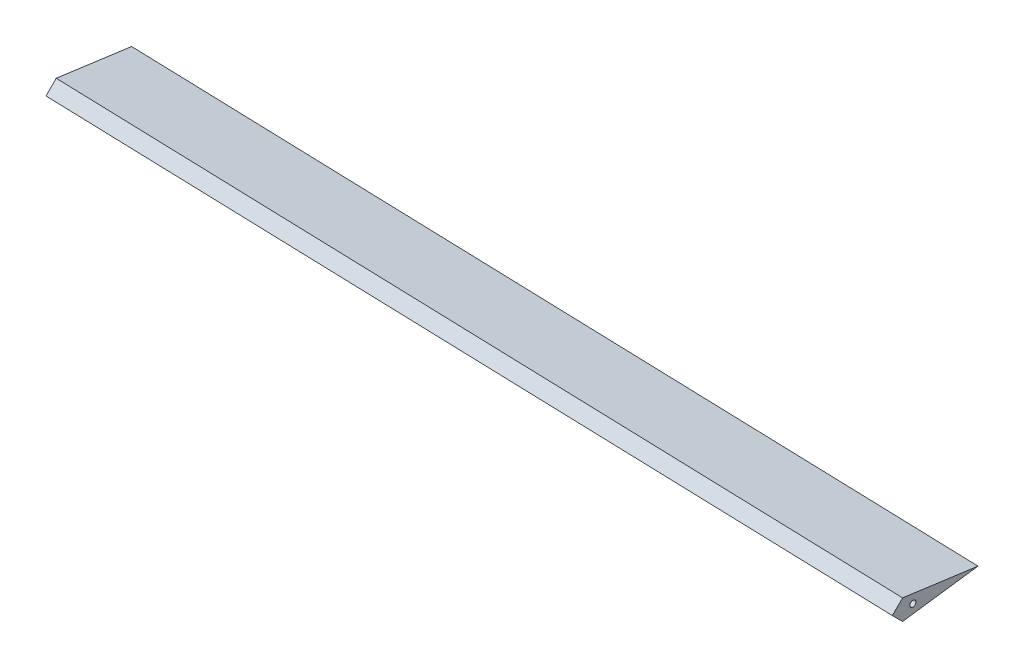
from build123d import *

# Parameters (mm, degrees)
AILERON_DEPTH           = 402.822020631
SKETCH2_R               = 2.75
CUT_EXTRUDE2_DEPTH      = 403.822020631
CUT_EXTRUDE2_DEPTH_BACK = 406.280098


with BuildPart() as part:
    # aileron_root → aileron (new body, symmetric, along a direction that is not the sketch's normal)
    with BuildSketch(Plane(origin=(0, 0, 0), x_dir=(0, 0, -1), z_dir=(1, 0, 0))):
        Polygon((-80, -10.846932253), (-80, 10.846932253), (0, 0), align=None)
    extrude(amount=AILERON_DEPTH, dir=(0.999527846, 0, 0.030725967), both=True)

    # Sketch2 → Cut-Extrude2 (cut, two sides)
    with BuildSketch(Plane(origin=(0, 0, 0), x_dir=(-0.030725967, 0, 0.999527846), z_dir=(-0.999527846, 0, -0.030725967))) as cut_extrude2_sk:
        with Locations((60, 0)):
            Circle(SKETCH2_R)
        Polygon((78.962227681, 0), (68.115295428, -10.846932253), (79.962227681, -10.846932253), (79.962227681, 10.846932253), (68.115295428, 10.846932253), align=None)
    extrude(amount=CUT_EXTRUDE2_DEPTH, mode=Mode.SUBTRACT)
    extrude(cut_extrude2_sk.sketch, amount=-CUT_EXTRUDE2_DEPTH_BACK, mode=Mode.SUBTRACT)


solid = part.part
